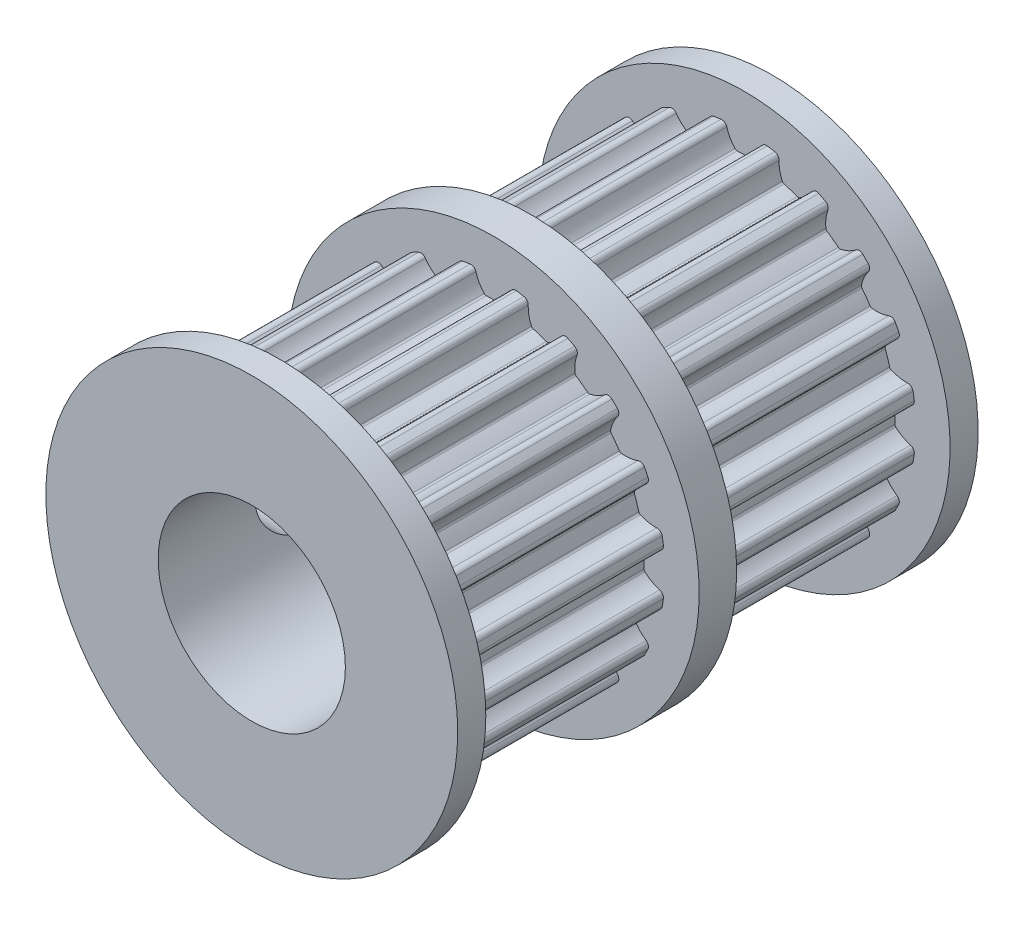
from build123d import *

# Parameters (mm, degrees)
SKETCH_1_R               = 9.17
EXTRUDE_1_DEPTH          = 12.4
CUT_EXTRUDE_START        = -25.8
CUT_EXTRUDE_1_DEPTH      = 26.8
PATTERN_CIRCULAR_1_COUNT = 20
SKETCH_3_R               = 11
EXTRUDE_2_DEPTH          = 1.5
SKETCH_9_R               = 11
EXTRUDE_3_DEPTH          = 1.5
EXTRUDE_START            = -12.4
SKETCH_12_R              = 11
EXTRUDE_4_DEPTH          = 1
SKETCH_4_R               = 5
CUT_EXTRUDE_2_DEPTH      = 28.8
SKETCH_11_R              = 2.1
CUT_EXTRUDE_4_DEPTH      = 12


with BuildPart() as part:
    # 草圖1 → 填料-伸長1 (new body, symmetric)
    with BuildSketch(Plane.XY):
        Circle(SKETCH_1_R)
    extrude(amount=EXTRUDE_1_DEPTH, both=True)

    # 草圖2 → 除料-伸長1 (cut)
    with BuildSketch(Plane.XY.offset(12.4).offset(CUT_EXTRUDE_START)):
        with BuildLine():
            ThreePointArc((-0.372835703, 8.051372153), (0, 8.06), (0.372835703, 8.051372153))
            ThreePointArc((0.372835703, 8.051372153), (0.437515299, 8.062770331), (0.491125647, 8.100708427))
            ThreePointArc((0.491125647, 8.100708427), (0.753329245, 8.468226481), (0.925222062, 8.885686787))
            ThreePointArc((0.925222062, 8.885686787), (1.041179318, 9.043582036), (1.232246479, 9.086829404))
            ThreePointArc((1.232246479, 9.086829404), (0, 9.17), (-1.232246479, 9.086829404))
            ThreePointArc((-1.232246479, 9.086829404), (-1.041179318, 9.043582036), (-0.925222062, 8.885686787))
            ThreePointArc((-0.925222062, 8.885686787), (-0.753329245, 8.468226481), (-0.491125647, 8.100708427))
            ThreePointArc((-0.491125647, 8.100708427), (-0.437515299, 8.062770331), (-0.372835703, 8.051372153))
        make_face()
    cut_extrude_1 = extrude(amount=CUT_EXTRUDE_1_DEPTH, mode=Mode.SUBTRACT)

    # 環狀複製排列1: 除料-伸長1 ×20 about axis
    pattern_circular_1_axis = Axis((0, 0, 0), (0, 0, 1))
    for i in range(1, PATTERN_CIRCULAR_1_COUNT):
        add(cut_extrude_1.rotate(pattern_circular_1_axis, i * 360 / PATTERN_CIRCULAR_1_COUNT), mode=Mode.SUBTRACT)

    # 草圖3 → 填料-伸長2 (add)
    with BuildSketch(Plane.XY.offset(12.4)):
        Circle(SKETCH_3_R)
    extrude(amount=EXTRUDE_2_DEPTH)

    # 草圖9 → 填料-伸長3 (add)
    with BuildSketch(Plane(origin=(0, 0, -12.4), x_dir=(-1, 0, 0), z_dir=(0, 0, -1))):
        Circle(SKETCH_9_R)
    extrude(amount=EXTRUDE_3_DEPTH)

    # 草圖12 → 填料-伸長4 (add, symmetric)
    with BuildSketch(Plane.XY.offset(12.4).offset(EXTRUDE_START)):
        Circle(SKETCH_12_R)
    extrude(amount=EXTRUDE_4_DEPTH, both=True)

    # 草圖4 → 除料-伸長2 (cut, through all)
    with BuildSketch(Plane.XY.offset(13.9)):
        Circle(SKETCH_4_R)
    extrude(amount=-CUT_EXTRUDE_2_DEPTH, mode=Mode.SUBTRACT)

    # 草圖11 → 除料-伸長4 (cut, through all)
    with BuildSketch(Plane(origin=(0, 0, 0), x_dir=(0, 0, -1), z_dir=(1, 0, 0))):
        with Locations((6.6, 0)):
            Circle(SKETCH_11_R)
        with Locations((-6.6, 0)):
            Circle(SKETCH_11_R)
    extrude(amount=-CUT_EXTRUDE_4_DEPTH, mode=Mode.SUBTRACT)


solid = part.part
